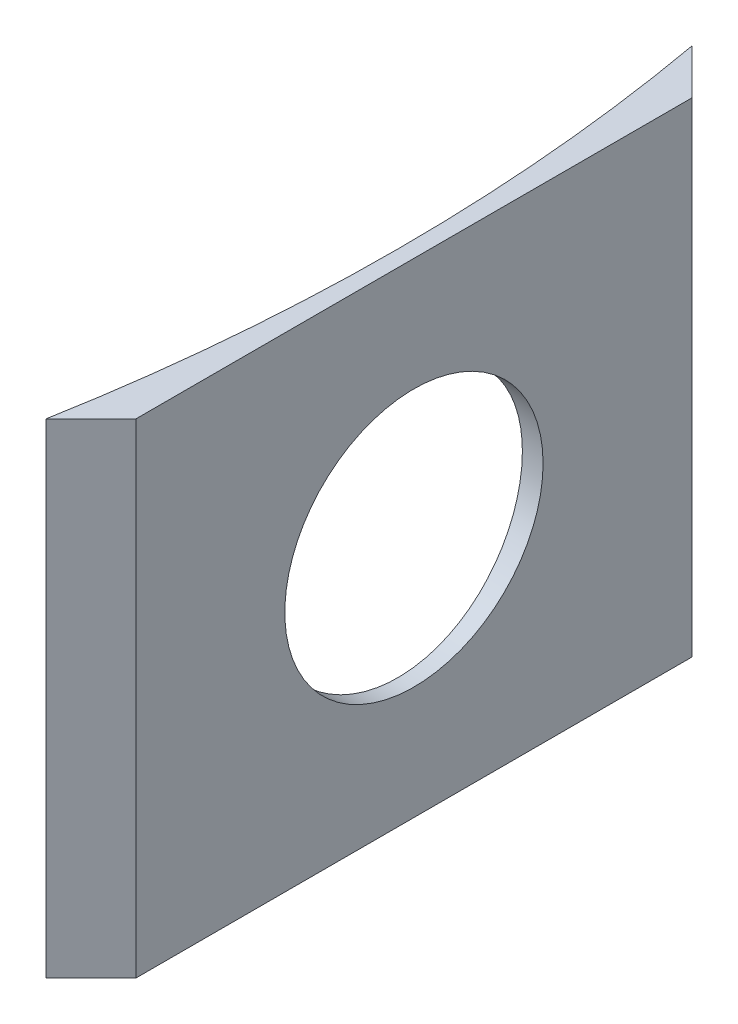
from build123d import *

# Parameters (mm, degrees)
BOSS_EXTRUDE1_DEPTH = 15
CUT_EXTRUDE1_DEPTH  = 25


with BuildPart() as part:
    # Sketch1 → Boss-Extrude1 (new body)
    with BuildSketch(Plane(origin=(0, 0, 0), x_dir=(1, 0, 0), z_dir=(0, 1, 0))):
        with BuildLine():
            ThreePointArc((55.608003021, 10), (56.276558933, 5.019852055), (56.5, 0))
            ThreePointArc((56.5, 0), (56.276558933, -5.019852055), (55.608003021, -10))
            Line((55.608003021, -10), (57, -8.608003021))
            Line((57, -8.608003021), (57, 8.608003021))
            Line((57, 8.608003021), (55.608003021, 10))
        make_face()
    extrude(amount=BOSS_EXTRUDE1_DEPTH)

    # Sketch2 → Cut-Extrude1 (cut)
    with BuildSketch(Plane(origin=(67, 0, 0), x_dir=(0, 0, -1), z_dir=(1, 0, 0))):
        with BuildLine():
            ThreePointArc((0, 11.5), (-4, 7.5), (0, 3.5))
            Line((0, 3.5), (0, 11.5))
        make_face()
        with BuildLine():
            Line((0, 11.5), (0, 3.5))
            ThreePointArc((0, 3.5), (2.828427125, 4.671572875), (4, 7.5))
            ThreePointArc((4, 7.5), (2.828427125, 10.328427125), (0, 11.5))
        make_face()
    extrude(amount=-CUT_EXTRUDE1_DEPTH, mode=Mode.SUBTRACT)


solid = part.part
